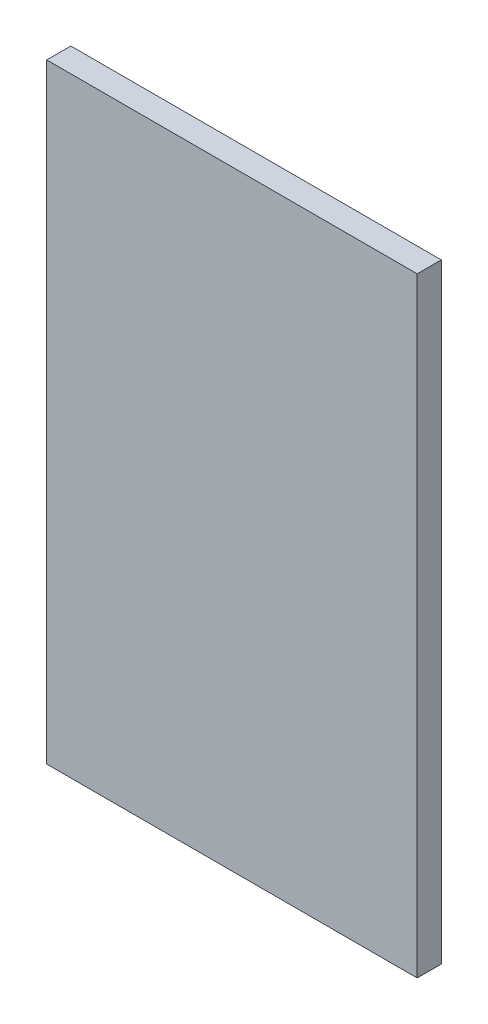
from build123d import *

# Parameters (mm, degrees)
EXTRUDE_1_DEPTH      = 790
EXTRUDE_1_DEPTH_BACK = 790
SKETCH_1_W           = 24300
SKETCH_1_H           = 40000


with BuildPart() as part:
    # Эскиз1 → Бобышка-Вытянуть1 (new, two sides: drawn at the far end of the back side and taken through both)
    with BuildSketch(Plane.XY.offset(-EXTRUDE_1_DEPTH_BACK)):
        with Locations((-160.709634714, 928.155119886)):
            Rectangle(SKETCH_1_W, SKETCH_1_H)
    extrude(amount=EXTRUDE_1_DEPTH + EXTRUDE_1_DEPTH_BACK)


solid = part.part
